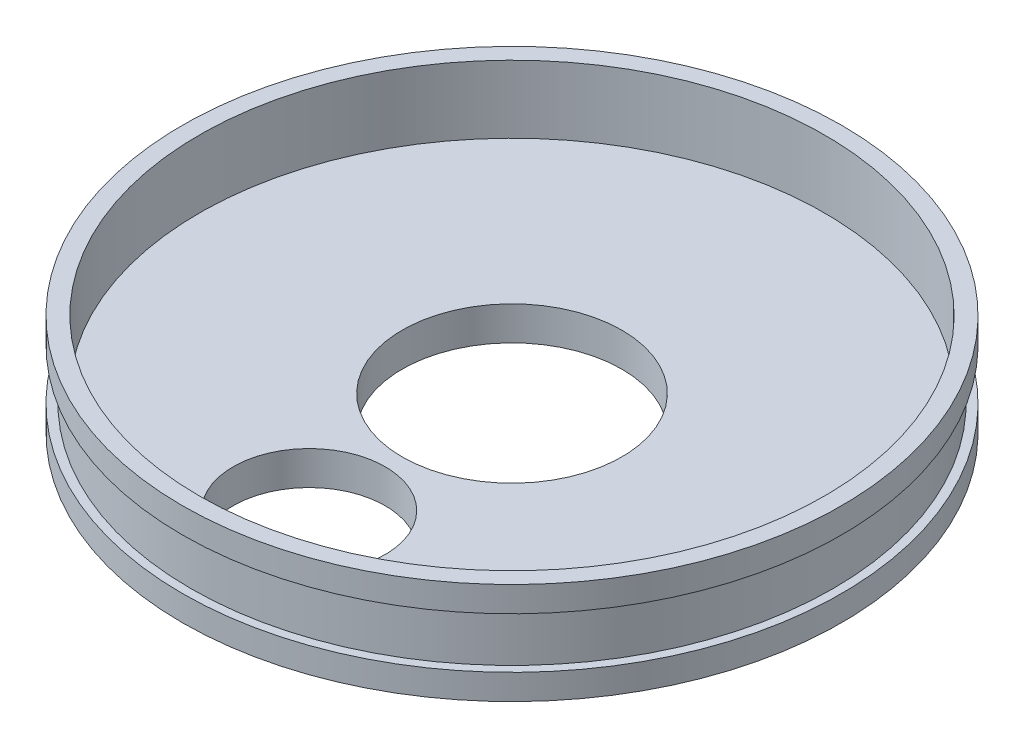
from build123d import *

# Parameters (mm, degrees)
SKETCH2_R      = 19.5
SKETCH2_R_2    = 4.5
SKETCH2_R_3    = 6.5
LIDBASE_DEPTH  = 2
SKETCH2_4_R    = 19.5
SKETCH2_4_R_2  = 18.5
LIDWALLS_DEPTH = 6
SKETCH3_W      = 0.5
SKETCH3_H      = 3


with BuildPart() as part:
    # Sketch2 → LidBase (new body)
    with BuildSketch(Plane(origin=(0, 0, 0), x_dir=(1, 0, 0), z_dir=(0, 1, 0))):
        Circle(SKETCH2_R)
        with Locations((0, -12)):
            Circle(SKETCH2_R_2, mode=Mode.SUBTRACT)
        Circle(SKETCH2_R_3, mode=Mode.SUBTRACT)
    extrude(amount=LIDBASE_DEPTH)

    # Sketch2_4 → LidWalls (add)
    with BuildSketch(Plane(origin=(0, 0, 0), x_dir=(1, 0, 0), z_dir=(0, 1, 0))):
        Circle(SKETCH2_4_R)
        Circle(SKETCH2_4_R_2, mode=Mode.SUBTRACT)
    extrude(amount=LIDWALLS_DEPTH)

    # Sketch3 → Beltgrooves (revolve, cut)
    with BuildSketch(Plane(origin=(0, 0, 0), x_dir=(0, 0, -1), z_dir=(1, 0, 0))):
        with Locations((19.25, 3)):
            Rectangle(SKETCH3_W, SKETCH3_H)
    revolve(axis=Axis((0, 0, 0), (0, 1, 0)), mode=Mode.SUBTRACT)


solid = part.part
